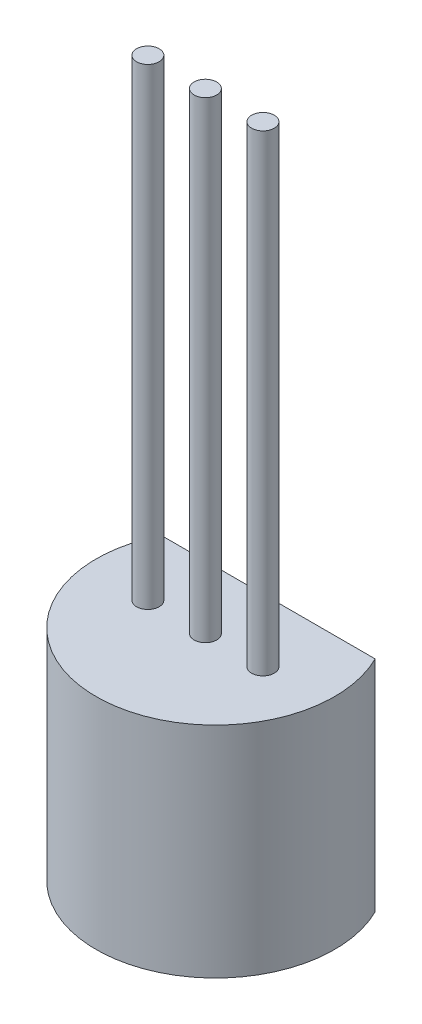
from build123d import *

# Parameters (mm, degrees)
BOSS_EXTRUDE1_DEPTH = 5.33
SKETCH2_R           = 0.275
BOSS_EXTRUDE2_DEPTH = 11.48431719


with BuildPart() as part:
    # Sketch1 → Boss-Extrude1 (new body)
    with BuildSketch(Plane(origin=(0, 0, 0), x_dir=(1, 0, 0), z_dir=(0, 1, 0))):
        with BuildLine():
            Line((-2.6, 0), (2.6, 0))
            ThreePointArc((2.6, 0), (0, -4.19), (-2.6, 0))
        make_face()
    extrude(amount=BOSS_EXTRUDE1_DEPTH)

    # Sketch2 → Boss-Extrude2 (add)
    with BuildSketch(Plane(origin=(0, 5.33, 0), x_dir=(1, 0, 0), z_dir=(0, 1, 0))):
        with Locations((0, -1.53)):
            Circle(SKETCH2_R)
        with Locations((-1.4, -1.53)):
            Circle(SKETCH2_R)
        with Locations((1.4, -1.53)):
            Circle(SKETCH2_R)
    extrude(amount=BOSS_EXTRUDE2_DEPTH)


solid = part.part
